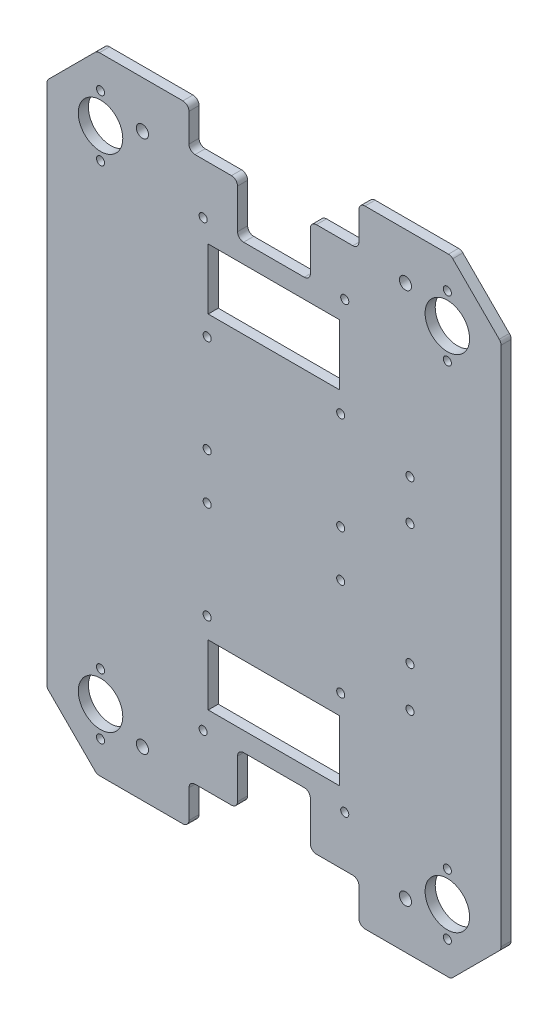
from build123d import *

# Parameters (mm, degrees)
BASE_DEPTH                = 5
ESQUISSE3_R               = 2
ESQUISSE3_W               = 65
ESQUISSE3_H               = 30
ENL_V_MAT_EXTRU_1_DEPTH   = 6
CONG_1_R                  = 3
PER_AGE_POUR_BILLES_REACH = 7
ESQUISSE6_R               = 2
ESQUISSE6_R_2             = 11
PER_AGE_POUR_PROFIL_REACH = 7
ESQUISSE8_R               = 3
ESQUISSE10_R              = 2
ENL_V_MAT_EXTRU_3_DEPTH   = 6
ESQUISSE13_R              = 2
ENL_V_MAT_EXTRU_4_DEPTH   = 10


with BuildPart() as part:
    # Esquisse1 → Base (new body)
    with BuildSketch(Plane.XY):
        Polygon((0, 0), (-175, 0), (-199.748737342, 24.748737342), (-199.748737342, 284.748737342), (-175, 309.497474683), (0, 309.497474683), (24.748737342, 284.748737342), (24.748737342, 24.748737342), align=None)
    extrude(amount=BASE_DEPTH)

    # Esquisse3 → Enlèv. mat.-Extru.1 (cut, through all)
    with BuildSketch(Plane(origin=(0, 0, 0), x_dir=(-1, 0, 0), z_dir=(0, 0, -1))):
        with Locations((52.5, 45)):
            Circle(ESQUISSE3_R)
        with Locations((122.5, 45)):
            Circle(ESQUISSE3_R)
        with Locations((122.5, 264.497474683)):
            Circle(ESQUISSE3_R)
        with Locations((52.5, 264.497474683)):
            Circle(ESQUISSE3_R)
        Polygon((129.5, 0), (129.5, 20), (105.5, 20), (105.5, 45.5), (69.5, 45.5), (69.5, 20), (45.5, 20), (45.5, 0), align=None)
        Polygon((45.5, 309.497474683), (129.5, 309.497474683), (129.5, 289.497474683), (105.5, 289.497474683), (105.5, 263.997474683), (69.5, 263.997474683), (69.5, 289.497474683), (45.5, 289.497474683), align=None)
        with Locations((87.5, 239.497474683)):
            Rectangle(ESQUISSE3_W, ESQUISSE3_H)
        with Locations((87.5, 70)):
            Rectangle(ESQUISSE3_W, ESQUISSE3_H)
    extrude(amount=-ENL_V_MAT_EXTRU_1_DEPTH, mode=Mode.SUBTRACT)

    # Congé1
    cong_1_edges = [part.edges().sort_by_distance(p)[0] for p in [
        (0, 0, 2.5),
        (-175, 0, 2.5),
        (-199.748737342, 24.748737342, 2.5),
        (-199.748737342, 284.748737342, 2.5),
        (-175, 309.497474683, 2.5),
        (0, 309.497474683, 2.5),
        (24.748737342, 284.748737342, 2.5),
        (24.748737342, 24.748737342, 2.5),
        (-45.5, 289.497474683, 2.5),
        (-45.5, 309.497474683, 2.5),
        (-129.5, 309.497474683, 2.5),
        (-129.5, 289.497474683, 2.5),
        (-105.5, 289.497474683, 2.5),
        (-105.5, 263.997474683, 2.5),
        (-69.5, 263.997474683, 2.5),
        (-69.5, 289.497474683, 2.5),
        (-129.5, 0, 2.5),
        (-45.5, 0, 2.5),
        (-45.5, 20, 2.5),
        (-69.5, 20, 2.5),
        (-69.5, 45.5, 2.5),
        (-105.5, 45.5, 2.5),
        (-105.5, 20, 2.5),
        (-129.5, 20, 2.5),
    ]]
    fillet(cong_1_edges, radius=CONG_1_R)

    # Esquisse6 → Perçage pour billes (cut, up to next)
    with BuildSketch(Plane.XY.offset(5), mode=Mode.PRIVATE) as per_age_pour_billes_sk1:
        with Locations((-1.784271247, 16)):
            Circle(ESQUISSE6_R)
    per_age_pour_billes_tool1 = extrude(per_age_pour_billes_sk1.sketch, amount=-PER_AGE_POUR_BILLES_REACH, mode=Mode.PRIVATE) & part.part
    add(per_age_pour_billes_tool1.solids().sort_by_distance((-1.784271, 16, 5))[0], mode=Mode.SUBTRACT)
    # Esquisse6 → Perçage pour billes (cut, up to next)
    with BuildSketch(Plane.XY.offset(5), mode=Mode.PRIVATE) as per_age_pour_billes_sk2:
        with Locations((-1.784271247, 46)):
            Circle(ESQUISSE6_R)
    per_age_pour_billes_tool2 = extrude(per_age_pour_billes_sk2.sketch, amount=-PER_AGE_POUR_BILLES_REACH, mode=Mode.PRIVATE) & part.part
    add(per_age_pour_billes_tool2.solids().sort_by_distance((-1.784271, 46, 5))[0], mode=Mode.SUBTRACT)
    # Esquisse6 → Perçage pour billes (cut, up to next)
    with BuildSketch(Plane.XY.offset(5), mode=Mode.PRIVATE) as per_age_pour_billes_sk3:
        with Locations((-1.784271247, 263.497474683)):
            Circle(ESQUISSE6_R)
    per_age_pour_billes_tool3 = extrude(per_age_pour_billes_sk3.sketch, amount=-PER_AGE_POUR_BILLES_REACH, mode=Mode.PRIVATE) & part.part
    add(per_age_pour_billes_tool3.solids().sort_by_distance((-1.784271, 263.497475, 5))[0], mode=Mode.SUBTRACT)
    # Esquisse6 → Perçage pour billes (cut, up to next)
    with BuildSketch(Plane.XY.offset(5), mode=Mode.PRIVATE) as per_age_pour_billes_sk4:
        with Locations((-1.784271247, 293.497474683)):
            Circle(ESQUISSE6_R)
    per_age_pour_billes_tool4 = extrude(per_age_pour_billes_sk4.sketch, amount=-PER_AGE_POUR_BILLES_REACH, mode=Mode.PRIVATE) & part.part
    add(per_age_pour_billes_tool4.solids().sort_by_distance((-1.784271, 293.497475, 5))[0], mode=Mode.SUBTRACT)
    # Esquisse6 → Perçage pour billes (cut, up to next)
    with BuildSketch(Plane.XY.offset(5), mode=Mode.PRIVATE) as per_age_pour_billes_sk5:
        with Locations((-1.784271247, 278.497474683)):
            Circle(ESQUISSE6_R_2)
    per_age_pour_billes_tool5 = extrude(per_age_pour_billes_sk5.sketch, amount=-PER_AGE_POUR_BILLES_REACH, mode=Mode.PRIVATE) & part.part
    add(per_age_pour_billes_tool5.solids().sort_by_distance((-1.784271, 278.497475, 5))[0], mode=Mode.SUBTRACT)
    # Esquisse6 → Perçage pour billes (cut, up to next)
    with BuildSketch(Plane.XY.offset(5), mode=Mode.PRIVATE) as per_age_pour_billes_sk6:
        with Locations((-1.784271247, 31)):
            Circle(ESQUISSE6_R_2)
    per_age_pour_billes_tool6 = extrude(per_age_pour_billes_sk6.sketch, amount=-PER_AGE_POUR_BILLES_REACH, mode=Mode.PRIVATE) & part.part
    add(per_age_pour_billes_tool6.solids().sort_by_distance((-1.784271, 31, 5))[0], mode=Mode.SUBTRACT)
    # Esquisse6 → Perçage pour billes (cut, up to next)
    with BuildSketch(Plane.XY.offset(5), mode=Mode.PRIVATE) as per_age_pour_billes_sk7:
        with Locations((-173.215728753, 16)):
            Circle(ESQUISSE6_R)
    per_age_pour_billes_tool7 = extrude(per_age_pour_billes_sk7.sketch, amount=-PER_AGE_POUR_BILLES_REACH, mode=Mode.PRIVATE) & part.part
    add(per_age_pour_billes_tool7.solids().sort_by_distance((-173.215729, 16, 5))[0], mode=Mode.SUBTRACT)
    # Esquisse6 → Perçage pour billes (cut, up to next)
    with BuildSketch(Plane.XY.offset(5), mode=Mode.PRIVATE) as per_age_pour_billes_sk8:
        with Locations((-173.215728753, 46)):
            Circle(ESQUISSE6_R)
    per_age_pour_billes_tool8 = extrude(per_age_pour_billes_sk8.sketch, amount=-PER_AGE_POUR_BILLES_REACH, mode=Mode.PRIVATE) & part.part
    add(per_age_pour_billes_tool8.solids().sort_by_distance((-173.215729, 46, 5))[0], mode=Mode.SUBTRACT)
    # Esquisse6 → Perçage pour billes (cut, up to next)
    with BuildSketch(Plane.XY.offset(5), mode=Mode.PRIVATE) as per_age_pour_billes_sk9:
        with Locations((-173.215728753, 31)):
            Circle(ESQUISSE6_R_2)
    per_age_pour_billes_tool9 = extrude(per_age_pour_billes_sk9.sketch, amount=-PER_AGE_POUR_BILLES_REACH, mode=Mode.PRIVATE) & part.part
    add(per_age_pour_billes_tool9.solids().sort_by_distance((-173.215729, 31, 5))[0], mode=Mode.SUBTRACT)
    # Esquisse6 → Perçage pour billes (cut, up to next)
    with BuildSketch(Plane.XY.offset(5), mode=Mode.PRIVATE) as per_age_pour_billes_sk10:
        with Locations((-173.215728753, 263.497474683)):
            Circle(ESQUISSE6_R)
    per_age_pour_billes_tool10 = extrude(per_age_pour_billes_sk10.sketch, amount=-PER_AGE_POUR_BILLES_REACH, mode=Mode.PRIVATE) & part.part
    add(per_age_pour_billes_tool10.solids().sort_by_distance((-173.215729, 263.497475, 5))[0], mode=Mode.SUBTRACT)
    # Esquisse6 → Perçage pour billes (cut, up to next)
    with BuildSketch(Plane.XY.offset(5), mode=Mode.PRIVATE) as per_age_pour_billes_sk11:
        with Locations((-173.215728753, 293.497474683)):
            Circle(ESQUISSE6_R)
    per_age_pour_billes_tool11 = extrude(per_age_pour_billes_sk11.sketch, amount=-PER_AGE_POUR_BILLES_REACH, mode=Mode.PRIVATE) & part.part
    add(per_age_pour_billes_tool11.solids().sort_by_distance((-173.215729, 293.497475, 5))[0], mode=Mode.SUBTRACT)
    # Esquisse6 → Perçage pour billes (cut, up to next)
    with BuildSketch(Plane.XY.offset(5), mode=Mode.PRIVATE) as per_age_pour_billes_sk12:
        with Locations((-173.215728753, 278.497474683)):
            Circle(ESQUISSE6_R_2)
    per_age_pour_billes_tool12 = extrude(per_age_pour_billes_sk12.sketch, amount=-PER_AGE_POUR_BILLES_REACH, mode=Mode.PRIVATE) & part.part
    add(per_age_pour_billes_tool12.solids().sort_by_distance((-173.215729, 278.497475, 5))[0], mode=Mode.SUBTRACT)

    # Esquisse8 → Perçage pour profilé (cut, up to next)
    with BuildSketch(Plane.XY.offset(5), mode=Mode.PRIVATE) as per_age_pour_profil_sk1:
        with Locations((-152.5, 23)):
            Circle(ESQUISSE8_R)
    per_age_pour_profil_tool1 = extrude(per_age_pour_profil_sk1.sketch, amount=-PER_AGE_POUR_PROFIL_REACH, mode=Mode.PRIVATE) & part.part
    add(per_age_pour_profil_tool1.solids().sort_by_distance((-152.5, 23, 5))[0], mode=Mode.SUBTRACT)
    # Esquisse8 → Perçage pour profilé (cut, up to next)
    with BuildSketch(Plane.XY.offset(5), mode=Mode.PRIVATE) as per_age_pour_profil_sk2:
        with Locations((-152.5, 286.497474683)):
            Circle(ESQUISSE8_R)
    per_age_pour_profil_tool2 = extrude(per_age_pour_profil_sk2.sketch, amount=-PER_AGE_POUR_PROFIL_REACH, mode=Mode.PRIVATE) & part.part
    add(per_age_pour_profil_tool2.solids().sort_by_distance((-152.5, 286.497475, 5))[0], mode=Mode.SUBTRACT)
    # Esquisse8 → Perçage pour profilé (cut, up to next)
    with BuildSketch(Plane.XY.offset(5), mode=Mode.PRIVATE) as per_age_pour_profil_sk3:
        with Locations((-22.5, 286.497474683)):
            Circle(ESQUISSE8_R)
    per_age_pour_profil_tool3 = extrude(per_age_pour_profil_sk3.sketch, amount=-PER_AGE_POUR_PROFIL_REACH, mode=Mode.PRIVATE) & part.part
    add(per_age_pour_profil_tool3.solids().sort_by_distance((-22.5, 286.497475, 5))[0], mode=Mode.SUBTRACT)
    # Esquisse8 → Perçage pour profilé (cut, up to next)
    with BuildSketch(Plane.XY.offset(5), mode=Mode.PRIVATE) as per_age_pour_profil_sk4:
        with Locations((-22.5, 23)):
            Circle(ESQUISSE8_R)
    per_age_pour_profil_tool4 = extrude(per_age_pour_profil_sk4.sketch, amount=-PER_AGE_POUR_PROFIL_REACH, mode=Mode.PRIVATE) & part.part
    add(per_age_pour_profil_tool4.solids().sort_by_distance((-22.5, 23, 5))[0], mode=Mode.SUBTRACT)

    # Esquisse10 → Enlèv. mat.-Extru.3 (cut, through all)
    with BuildSketch(Plane.XY.offset(5)):
        with Locations((-120.5, 214.497474683)):
            Circle(ESQUISSE10_R)
        with Locations((-120.5, 166.197474683)):
            Circle(ESQUISSE10_R)
        with Locations((-54.5, 166.197474683)):
            Circle(ESQUISSE10_R)
        with Locations((-54.5, 214.497474683)):
            Circle(ESQUISSE10_R)
        with Locations((-54.5, 143.3)):
            Circle(ESQUISSE10_R)
        with Locations((-54.5, 95)):
            Circle(ESQUISSE10_R)
        with Locations((-120.5, 143.3)):
            Circle(ESQUISSE10_R)
        with Locations((-120.5, 95)):
            Circle(ESQUISSE10_R)
    extrude(amount=-ENL_V_MAT_EXTRU_3_DEPTH, mode=Mode.SUBTRACT)

    # Esquisse13 → Enlèv. mat.-Extru.4 (cut)
    with BuildSketch(Plane.XY.offset(5)):
        with Locations((-20.251262658, 204.748737342)):
            Circle(ESQUISSE13_R)
        with Locations((-20.251262658, 184.748737342)):
            Circle(ESQUISSE13_R)
        with Locations((-20.251262658, 124.748737342)):
            Circle(ESQUISSE13_R)
        with Locations((-20.251262658, 104.748737342)):
            Circle(ESQUISSE13_R)
    extrude(amount=-ENL_V_MAT_EXTRU_4_DEPTH, mode=Mode.SUBTRACT)


solid = part.part
